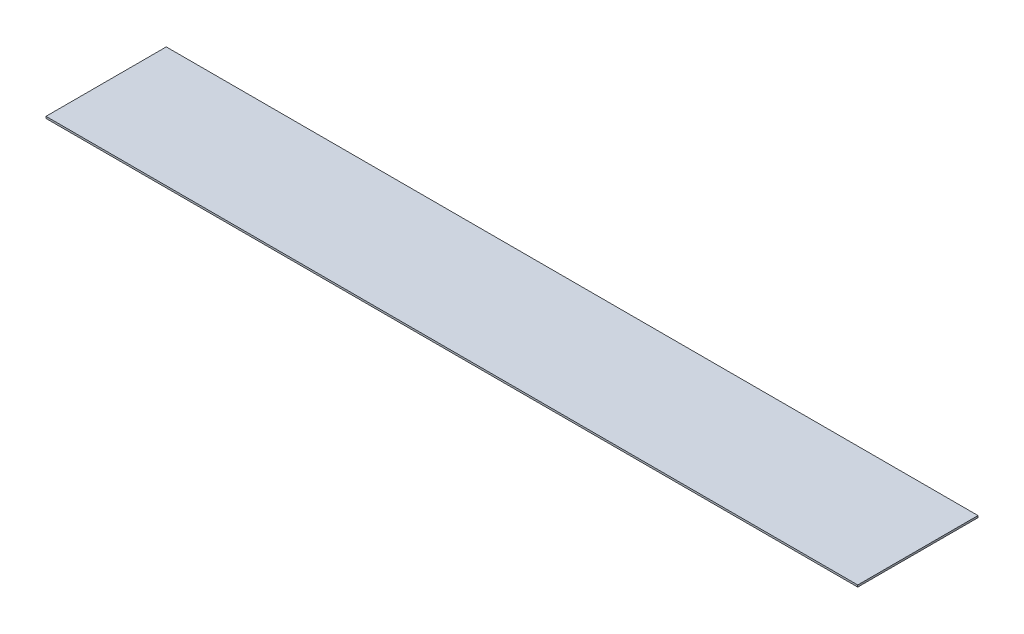
from build123d import *

# Parameters (mm, degrees)
SKETCH1_W           = 685.8
SKETCH1_H           = 101.6
BOSS_EXTRUDE1_DEPTH = 1.5875


with BuildPart() as part:
    # Sketch1 → Boss-Extrude1 (new body)
    with BuildSketch(Plane(origin=(0, 0, 0), x_dir=(1, 0, 0), z_dir=(0, 1, 0))):
        with Locations((342.9, 50.8)):
            Rectangle(SKETCH1_W, SKETCH1_H)
    extrude(amount=BOSS_EXTRUDE1_DEPTH)


solid = part.part
